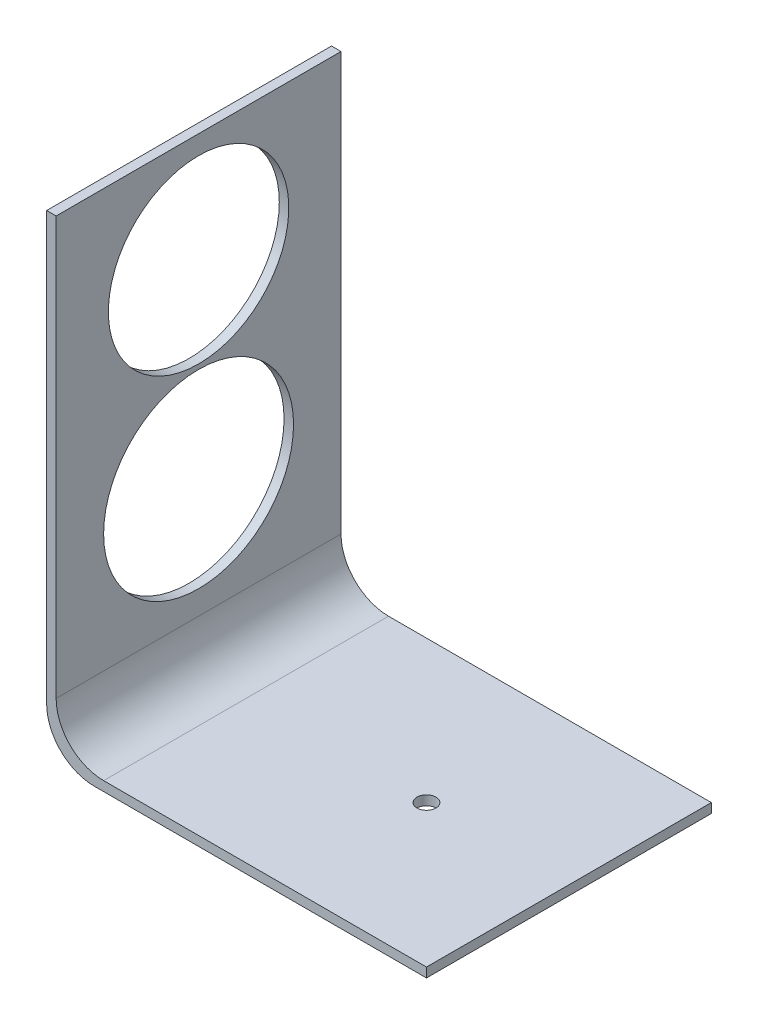
from build123d import *

# Parameters (mm, degrees)
BOSS_EXTRUDE1_DEPTH = 60
SKETCH2_R           = 20
SKETCH2_R_2         = 19
CUT_EXTRUDE1_DEPTH  = 10
SKETCH3_R           = 2
CUT_EXTRUDE2_DEPTH  = 10


with BuildPart() as part:
    # Sketch1 → Boss-Extrude1 (new body)
    with BuildSketch(Plane.XY):
        with BuildLine():
            Line((-24.827586207, 75.25862069), (-22.827586207, 75.25862069))
            Line((-22.827586207, 75.25862069), (-22.827586207, -12.74137931))
            ThreePointArc((-22.827586207, -12.74137931), (-19.898654019, -19.812447122), (-12.827586207, -22.74137931))
            Line((-12.827586207, -22.74137931), (55.172413793, -22.74137931))
            Line((55.172413793, -22.74137931), (55.172413793, -24.74137931))
            Line((55.172413793, -24.74137931), (-14.827586207, -24.74137931))
            ThreePointArc((-14.827586207, -24.74137931), (-21.898654019, -21.812447122), (-24.827586207, -14.74137931))
            Line((-24.827586207, -14.74137931), (-24.827586207, 75.25862069))
        make_face()
    extrude(amount=BOSS_EXTRUDE1_DEPTH)

    # Sketch2 → Cut-Extrude1 (cut)
    with BuildSketch(Plane(origin=(-22.827586207, 0, 0), x_dir=(0, 0, -1), z_dir=(1, 0, 0))):
        with Locations((-30, 12.25862069)):
            Circle(SKETCH2_R)
        with Locations((-30, 52.25862069)):
            Circle(SKETCH2_R_2)
    extrude(amount=-CUT_EXTRUDE1_DEPTH, mode=Mode.SUBTRACT)

    # Sketch3 → Cut-Extrude2 (cut)
    with BuildSketch(Plane(origin=(0, -22.74137931, 0), x_dir=(1, 0, 0), z_dir=(0, 1, 0))):
        with Locations((25.172413793, -30)):
            Circle(SKETCH3_R)
    extrude(amount=-CUT_EXTRUDE2_DEPTH, mode=Mode.SUBTRACT)


solid = part.part
